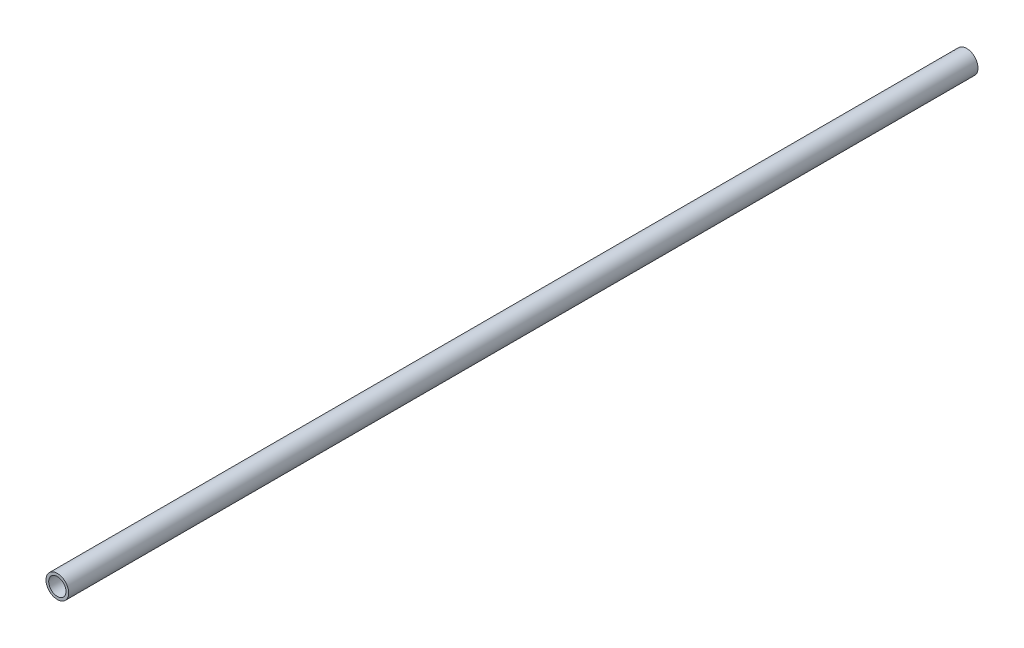
from build123d import *

# Parameters (mm, degrees)
ESQUISSE1_R        = 12.5
ESQUISSE1_R_2      = 9.5
BOSS_EXTRU_2_DEPTH = 1000


with BuildPart() as part:
    # Esquisse1 → Boss.-Extru.2 (new body)
    with BuildSketch(Plane.XY):
        Circle(ESQUISSE1_R)
        Circle(ESQUISSE1_R_2, mode=Mode.SUBTRACT)
    extrude(amount=BOSS_EXTRU_2_DEPTH)


solid = part.part
